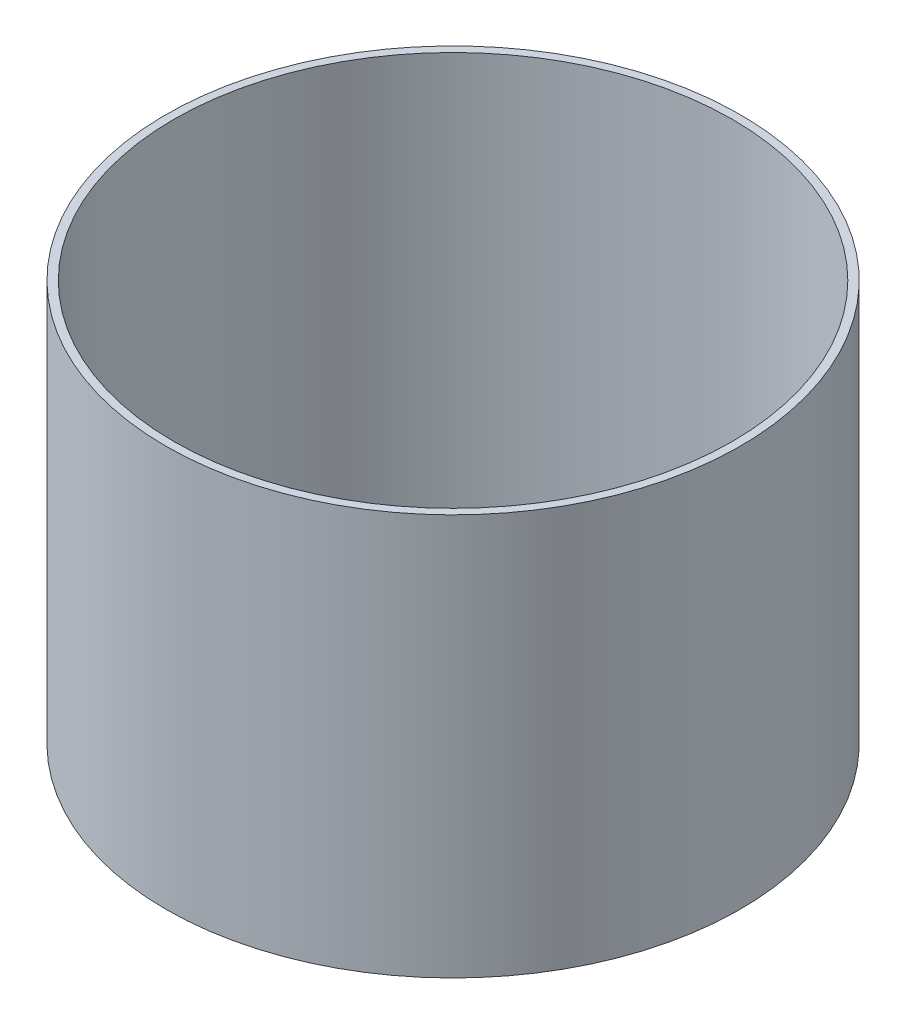
from build123d import *

# Parameters (mm, degrees)
SKETCH1_R           = 8.95
SKETCH1_R_2         = 8.7
BOSS_EXTRUDE1_DEPTH = 12.5


with BuildPart() as part:
    # Sketch1 → Boss-Extrude1 (new body)
    with BuildSketch(Plane(origin=(0, 0, 0), x_dir=(1, 0, 0), z_dir=(0, 1, 0))):
        Circle(SKETCH1_R)
        Circle(SKETCH1_R_2, mode=Mode.SUBTRACT)
    extrude(amount=BOSS_EXTRUDE1_DEPTH)


solid = part.part
